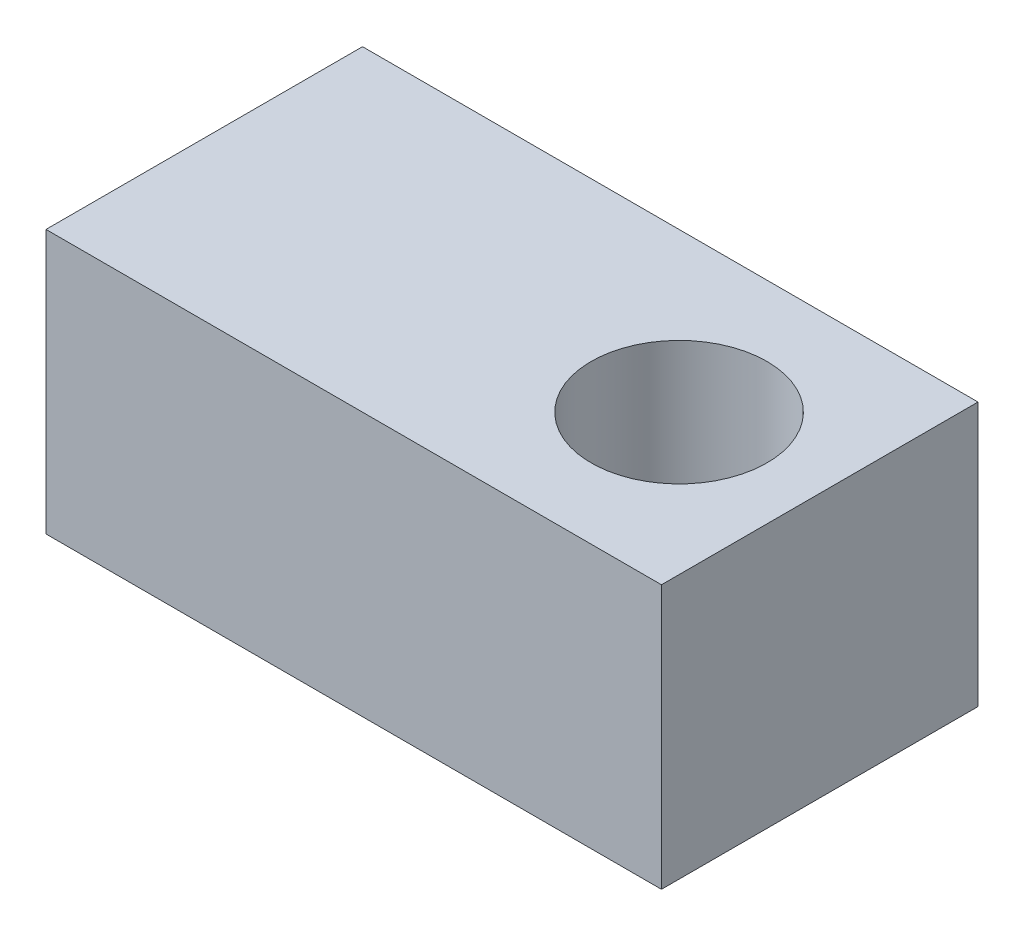
from build123d import *

# Parameters (mm, degrees)
SKETCH1_W           = 18
SKETCH1_H           = 15
BOSS_EXTRUDE1_DEPTH = 35
SKETCH2_R           = 5
CUT_EXTRUDE1_DEPTH  = 16
SKETCH3_R           = 3
CUT_EXTRUDE2_DEPTH  = 8


with BuildPart() as part:
    # Sketch1 → Boss-Extrude1 (new body)
    with BuildSketch(Plane(origin=(0, 0, 0), x_dir=(0, 0, -1), z_dir=(1, 0, 0))):
        with Locations((-18.782608696, 5.413043478)):
            Rectangle(SKETCH1_W, SKETCH1_H)
    extrude(amount=BOSS_EXTRUDE1_DEPTH)

    # Sketch2 → Cut-Extrude1 (cut, through all)
    with BuildSketch(Plane(origin=(0, -2.086956522, 0), x_dir=(-1, 0, 0), z_dir=(0, -1, 0))):
        with Locations((-27, -18.782608696)):
            Circle(SKETCH2_R)
    extrude(amount=-CUT_EXTRUDE1_DEPTH, mode=Mode.SUBTRACT)

    # Sketch3 → Cut-Extrude2 (cut)
    with BuildSketch(Plane.ZY):
        with Locations((18.782608696, 5.413043478)):
            Circle(SKETCH3_R)
    extrude(amount=-CUT_EXTRUDE2_DEPTH, mode=Mode.SUBTRACT)


solid = part.part
